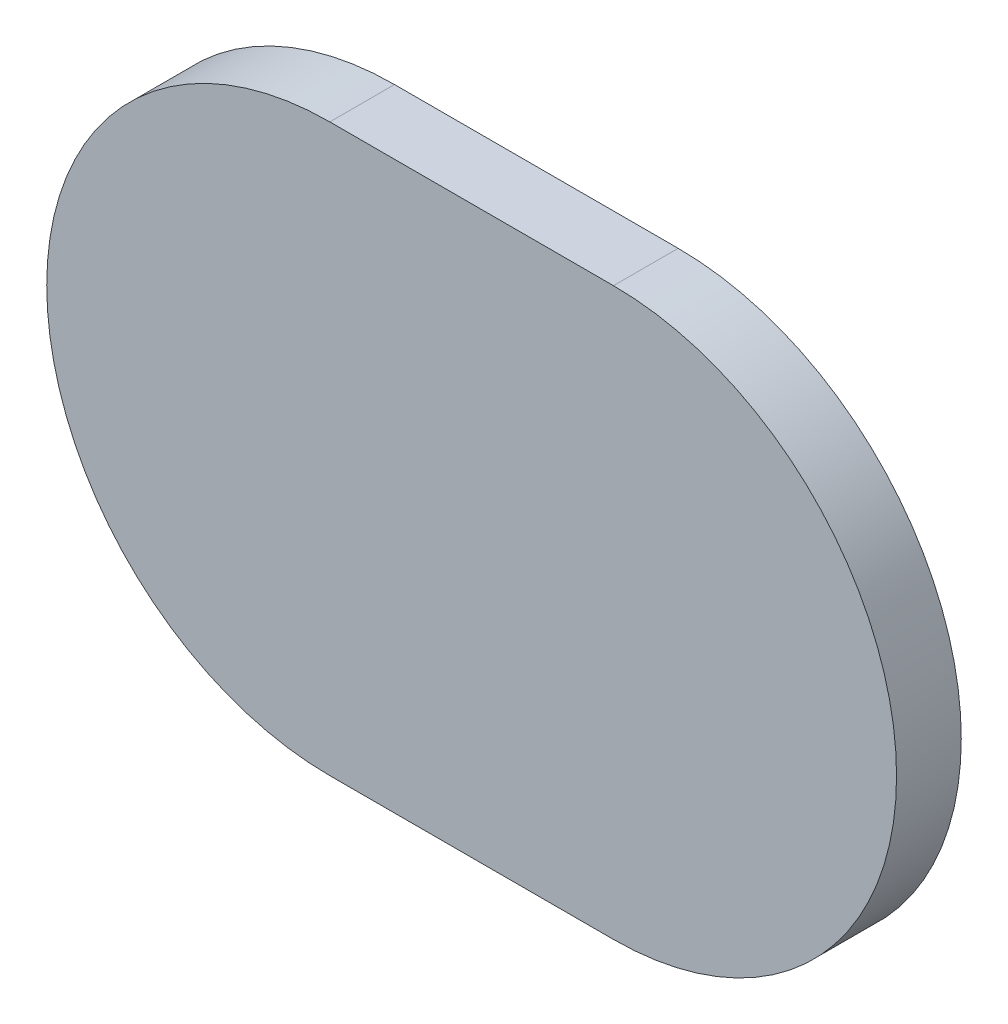
from build123d import *

# Parameters (mm, degrees)
BOSS_EXTRUDE1_DEPTH = 1.27


with BuildPart() as part:
    # Sketch1 → Boss-Extrude1 (new body)
    with BuildSketch(Plane.XY):
        with BuildLine():
            Line((0, 5.55625), (-5.56714, 5.55625))
            ThreePointArc((-5.56714, 5.55625), (-11.12339, 0), (-5.56714, -5.55625))
            Line((-5.56714, -5.55625), (0, -5.55625))
            ThreePointArc((0, -5.55625), (5.55625, 0), (0, 5.55625))
        make_face()
    extrude(amount=BOSS_EXTRUDE1_DEPTH)


solid = part.part
